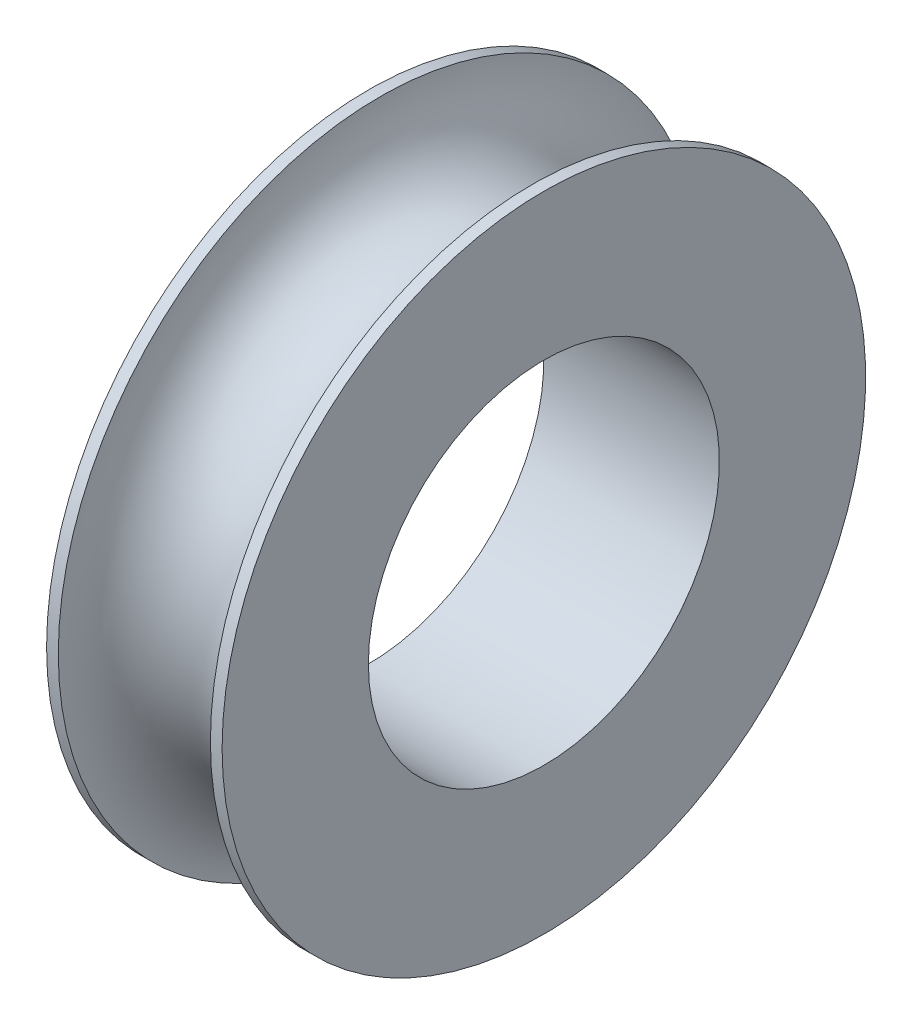
from build123d import *


with BuildPart() as part:
    # Sketch1 → Revolve1 (revolve)
    with BuildSketch(Plane(origin=(0, 0, 0), x_dir=(1, 0, 0), z_dir=(0, 1, 0))):
        with BuildLine():
            Line((0, 11), (0, 6))
            Line((0, 6), (6, 6))
            Line((6, 6), (6, 11))
            Line((6, 11), (5.6, 11))
            ThreePointArc((5.6, 11), (3, 8.4), (0.4, 11))
            Line((0.4, 11), (0, 11))
        make_face()
    revolve(axis=Axis((-8.532508904, 0, 0), (1, 0, 0)))


solid = part.part
